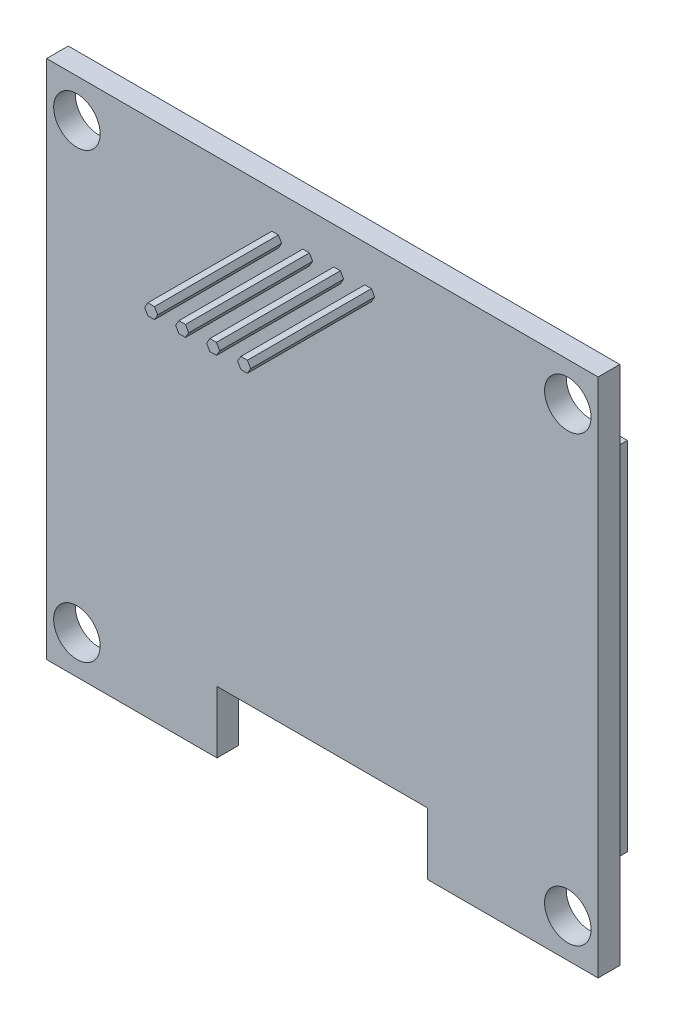
from build123d import *

# Parameters (mm, degrees)
SKETCH1_R           = 1.5
BOSS_EXTRUDE1_DEPTH = 1.4
SKETCH2_W           = 33.982309018
SKETCH2_H           = 23
BOSS_EXTRUDE2_DEPTH = 1.3
BOSS_EXTRUDE3_DEPTH = 8


with BuildPart() as part:
    # Sketch1 → Boss-Extrude1 (new body)
    with BuildSketch(Plane.XY):
        Polygon((17.8, 16.8), (-17.8, 16.8), (-17.8, -16.8), (-6.8, -16.8), (-6.8, -12.8), (6.8, -12.8), (6.8, -16.8), (17.8, -16.8), align=None)
        with Locations((-15.843700026, -14.313574824)):
            Circle(SKETCH1_R, mode=Mode.SUBTRACT)
        with Locations((15.843700026, -14.313574824)):
            Circle(SKETCH1_R, mode=Mode.SUBTRACT)
        with Locations((-15.843700026, 14.313574824)):
            Circle(SKETCH1_R, mode=Mode.SUBTRACT)
        with Locations((15.843700026, 14.313574824)):
            Circle(SKETCH1_R, mode=Mode.SUBTRACT)
    extrude(amount=BOSS_EXTRUDE1_DEPTH)

    # Sketch2 → Boss-Extrude2 (add)
    with BuildSketch(Plane(origin=(0, 0, 0), x_dir=(-1, 0, 0), z_dir=(0, 0, -1))):
        Rectangle(SKETCH2_W, SKETCH2_H)
    extrude(amount=BOSS_EXTRUDE2_DEPTH)

    # Sketch3 → Boss-Extrude3 (add)
    with BuildSketch(Plane.XY.offset(1.4)):
        Polygon((-0.625701938, 14.051390723), (-0.836940095, 14.417265944), (-1.259416409, 14.417265944), (-1.470654566, 14.051390723), (-1.259416409, 13.685515503), (-0.836940095, 13.685515503), align=None)
        Polygon((-2.625701938, 14.051390723), (-2.836940095, 14.417265944), (-3.259416409, 14.417265944), (-3.470654566, 14.051390723), (-3.259416409, 13.685515503), (-2.836940095, 13.685515503), align=None)
        Polygon((1.374298062, 14.051390723), (1.163059905, 14.417265944), (0.740583591, 14.417265944), (0.529345434, 14.051390723), (0.740583591, 13.685515503), (1.163059905, 13.685515503), align=None)
        Polygon((3.374298062, 14.051390723), (3.163059905, 14.417265944), (2.740583591, 14.417265944), (2.529345434, 14.051390723), (2.740583591, 13.685515503), (3.163059905, 13.685515503), align=None)
    extrude(amount=BOSS_EXTRUDE3_DEPTH)


solid = part.part
